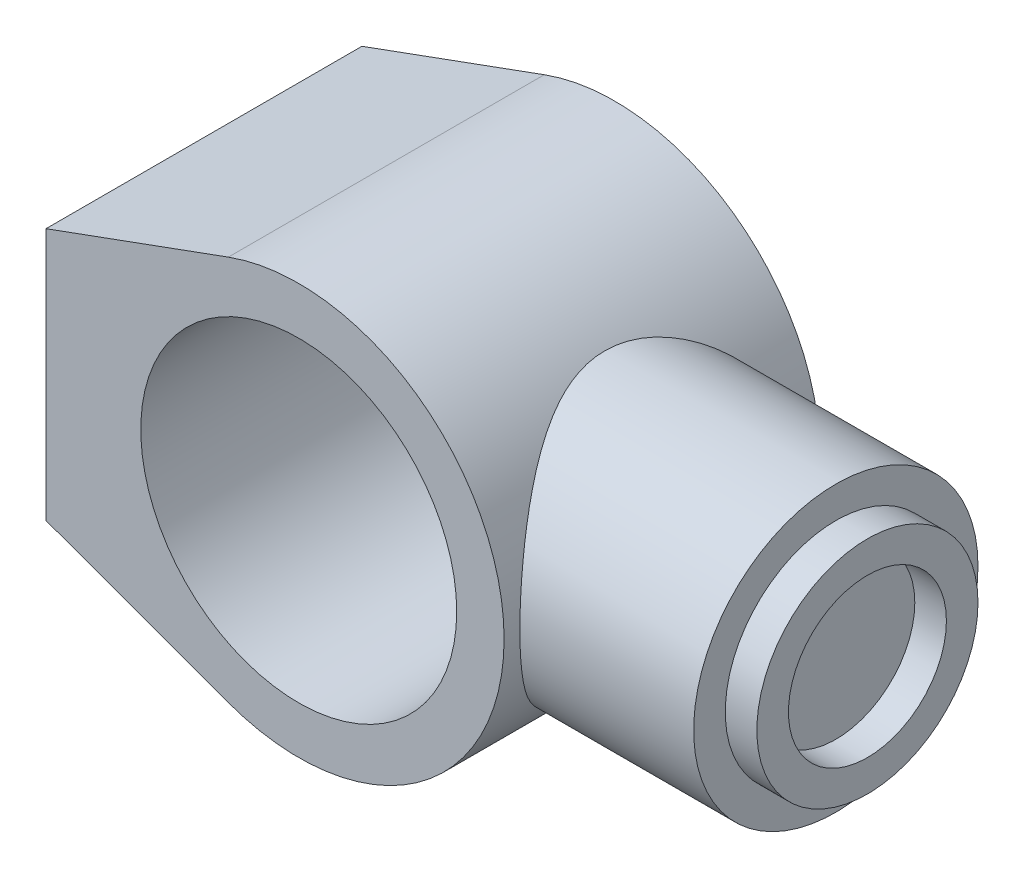
from build123d import *

# Parameters (mm, degrees)
SKETCH_1_R      = 50
EXTRUDE_1_DEPTH = 50
EXTRUDE_2_REACH = 202
SKETCH_2_R      = 45
SKETCH_3_R      = 35
SKETCH_3_R_2    = 25
EXTRUDE_3_DEPTH = 10


with BuildPart() as part:
    # 草图1 → 凸台-拉伸1 (new body, symmetric)
    with BuildSketch(Plane.XY):
        with BuildLine():
            Line((-80, 40), (-80, -40))
            Line((-80, -40), (-22.281665693, -61.061668614))
            ThreePointArc((-22.281665693, -61.061668614), (65, 0), (-22.281665693, 61.061668614))
            Line((-22.281665693, 61.061668614), (-80, 40))
        make_face()
        Circle(SKETCH_1_R, mode=Mode.SUBTRACT)
    extrude(amount=EXTRUDE_1_DEPTH, both=True)

    # 草图2 → 凸台-拉伸2 (add, up to next)
    with BuildSketch(Plane(origin=(120, 0, 0), x_dir=(0, 0, -1), z_dir=(1, 0, 0)), mode=Mode.PRIVATE) as extrude_2_sk1:
        Circle(SKETCH_2_R)
    extrude_2_tool1 = extrude(extrude_2_sk1.sketch, amount=-EXTRUDE_2_REACH, mode=Mode.PRIVATE) - part.part
    add(extrude_2_tool1.solids().sort_by_distance((120, 0, 0))[0])

    # 草图3 → 凸台-拉伸3 (add)
    with BuildSketch(Plane(origin=(120, 0, 0), x_dir=(0, 0, -1), z_dir=(1, 0, 0))):
        Circle(SKETCH_3_R)
        Circle(SKETCH_3_R_2, mode=Mode.SUBTRACT)
    extrude(amount=EXTRUDE_3_DEPTH)


solid = part.part
